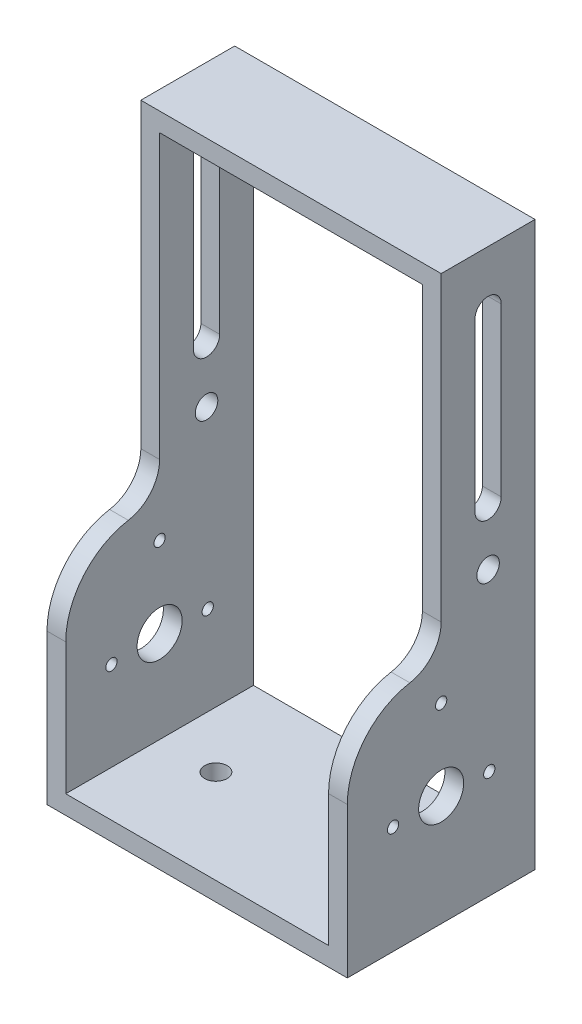
from build123d import *

# Parameters (mm, degrees)
SKETCH1_W               = 80
SKETCH1_H               = 150
SKETCH1_W_2             = 70
SKETCH1_H_2             = 140
EXTRUDE_THIN1_DEPTH     = 25
CUT_EXTRUDE1_DEPTH      = 1
CUT_EXTRUDE1_DEPTH_BACK = 81
FILLET1_R               = 20
SKETCH3_R               = 3
SKETCH3_R_2             = 1.5
SKETCH3_R_3             = 6
CUT_EXTRUDE2_DEPTH      = 1.0000001
CUT_EXTRUDE2_DEPTH_BACK = 81.0000001
SKETCH5_R               = 1.5
BOSS_EXTRUDE1_DEPTH     = 4
SKETCH6_R               = 3
CUT_EXTRUDE3_DEPTH      = 10


with BuildPart() as part:
    # Sketch1 → Extrude-Thin1 (new body, symmetric)
    with BuildSketch(Plane.XY):
        Rectangle(SKETCH1_W, SKETCH1_H)
        Rectangle(SKETCH1_W_2, SKETCH1_H_2, mode=Mode.SUBTRACT)
    extrude(amount=EXTRUDE_THIN1_DEPTH, both=True)

    # Sketch2 → Cut-Extrude1 (cut, two sides)
    with BuildSketch(Plane(origin=(40, 0, 0), x_dir=(0, 0, -1), z_dir=(1, 0, 0))) as cut_extrude1_sk:
        with BuildLine():
            Line((-25, -15.384333338), (-10, -15.384333338))
            ThreePointArc((-10, -15.384333338), (-2.928932188, -12.45540115), (0, -5.384333338))
            Line((0, -5.384333338), (0, 75))
            Line((0, 75), (-25, 75))
            Line((-25, 75), (-25, -15.384333338))
        make_face()
    extrude(amount=CUT_EXTRUDE1_DEPTH, mode=Mode.SUBTRACT)
    extrude(cut_extrude1_sk.sketch, amount=-CUT_EXTRUDE1_DEPTH_BACK, mode=Mode.SUBTRACT)

    # Fillet1
    fillet1_edges = [part.edges().sort_by_distance(p)[0] for p in [
        (-37.5, -15.384333338, 25),
        (37.5, -15.384333338, 25),
    ]]
    fillet(fillet1_edges, radius=FILLET1_R)

    # Sketch3 → Cut-Extrude2 (cut, two sides)
    with BuildSketch(Plane(origin=(40, 0, 0), x_dir=(0, 0, -1), z_dir=(1, 0, 0))) as cut_extrude2_sk:
        with Locations((12.5, 0.5)):
            Circle(SKETCH3_R)
        with Locations((0, -24.070063275)):
            Circle(SKETCH3_R_2)
        with Locations((12.817814142, -46.271168612)):
            Circle(SKETCH3_R_2)
        with Locations((0, -45.523799356)):
            Circle(SKETCH3_R_3)
        with Locations((-12.817814142, -46.271168612)):
            Circle(SKETCH3_R_2)
        with BuildLine():
            Line((16, 60), (16, 15.5))
            ThreePointArc((16, 15.5), (12.5, 12), (9, 15.5))
            Line((9, 15.5), (9, 60))
            ThreePointArc((9, 60), (12.5, 63.5), (16, 60))
        make_face()
    extrude(amount=CUT_EXTRUDE2_DEPTH, mode=Mode.SUBTRACT)
    extrude(cut_extrude2_sk.sketch, amount=-CUT_EXTRUDE2_DEPTH_BACK, mode=Mode.SUBTRACT)

    # Sketch5 → Boss-Extrude1 (add)
    with BuildSketch(Plane.XZ.offset(-70)):
        with Locations((0, -12.5)):
            Circle(SKETCH5_R)
    extrude(amount=BOSS_EXTRUDE1_DEPTH)

    # Sketch6 → Cut-Extrude3 (cut)
    with BuildSketch(Plane(origin=(0, -70, 0), x_dir=(1, 0, 0), z_dir=(0, 1, 0))):
        with Locations((20, 0)):
            Circle(SKETCH6_R)
        with Locations((-20, 0)):
            Circle(SKETCH6_R)
    extrude(amount=-CUT_EXTRUDE3_DEPTH, mode=Mode.SUBTRACT)


solid = part.part
